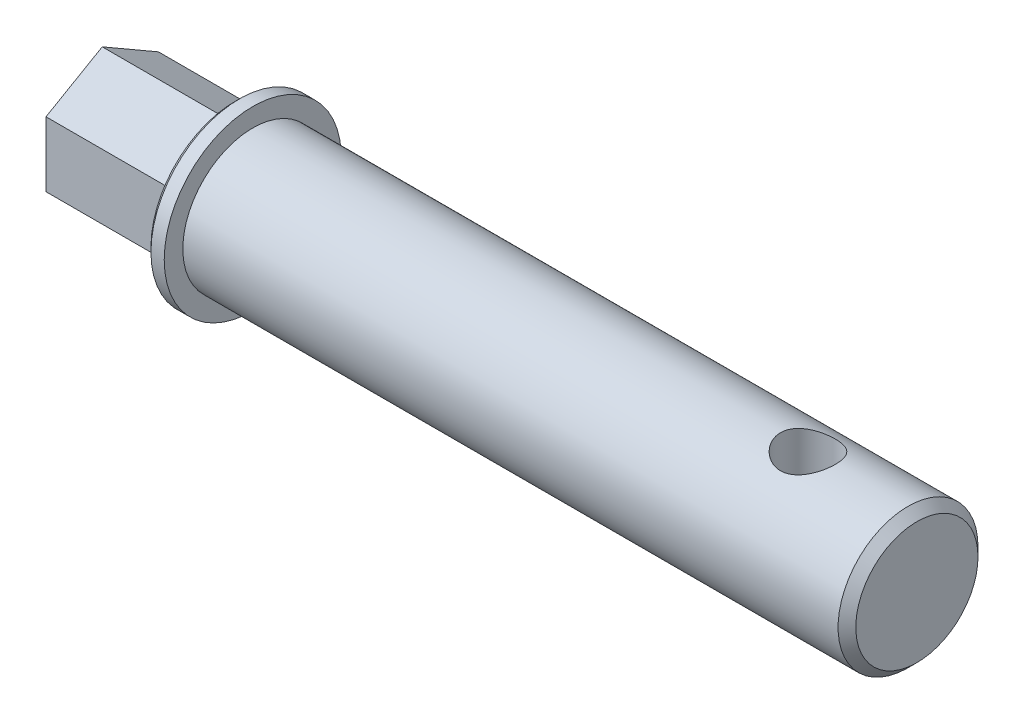
from build123d import *

# Parameters (mm, degrees)
SKETCH_1_R               = 7.9
EXTRUDE_1_DEPTH          = 75
SKETCH_3_R               = 10
EXTRUDE_2_DEPTH          = 2
EXTRUDE_3_DEPTH          = 15
CHAMFER_1_SIZE           = 0.5
M5X0_8_1_D               = 4.2
M5X0_8_1_DEPTH           = 12.4
M5X0_8_1_TIP             = 1.2618073
SKETCH_5_R               = 3.1
CUT_EXTRUDE_1_DEPTH      = 11
CUT_EXTRUDE_1_DEPTH_BACK = 11
CHAMFER_2_SIZE           = 1


with BuildPart() as part:
    # 草图1 → 凸台-拉伸1 (new body)
    with BuildSketch(Plane(origin=(0, 0, 0), x_dir=(0, 0, -1), z_dir=(1, 0, 0))):
        Circle(SKETCH_1_R)
    extrude(amount=EXTRUDE_1_DEPTH)

    # 草图3 → 凸台-拉伸2 (add)
    with BuildSketch(Plane.ZY):
        Circle(SKETCH_3_R)
    extrude(amount=EXTRUDE_2_DEPTH)

    # 草图4 → 凸台-拉伸3 (add)
    with BuildSketch(Plane.ZY.offset(2)):
        Polygon((6.35, 3.666174209), (0, 7.332348419), (-6.35, 3.666174209), (-6.35, -3.666174209), (0, -7.332348419), (6.35, -3.666174209), align=None)
    extrude(amount=EXTRUDE_3_DEPTH)

    # 倒角1
    chamfer_1_edges = [part.edges().sort_by_distance(p)[0] for p in [
        (-2, 0, -10),
    ]]
    chamfer(chamfer_1_edges, length=CHAMFER_1_SIZE)

    # M5x0.8 螺纹孔1
    with Locations(Plane.ZY.offset(17)):
        with Locations((0, 0)):
            Hole(M5X0_8_1_D / 2, depth=M5X0_8_1_DEPTH)
            with Locations((0, 0, -(M5X0_8_1_DEPTH + M5X0_8_1_TIP / 2))):  # 118° drill point
                Cone(0, M5X0_8_1_D / 2, M5X0_8_1_TIP, mode=Mode.SUBTRACT)

    # 草图5 → 切除-拉伸1 (cut, two sides)
    with BuildSketch(Plane(origin=(0, 0, 0), x_dir=(1, 0, 0), z_dir=(0, 1, 0))) as cut_extrude_1_sk:
        with Locations((62.7, 0)):
            Circle(SKETCH_5_R)
    extrude(amount=CUT_EXTRUDE_1_DEPTH, mode=Mode.SUBTRACT)
    extrude(cut_extrude_1_sk.sketch, amount=-CUT_EXTRUDE_1_DEPTH_BACK, mode=Mode.SUBTRACT)

    # 倒角2
    chamfer_2_edges = [part.edges().sort_by_distance(p)[0] for p in [
        (75, 0, 7.9),
    ]]
    chamfer(chamfer_2_edges, length=CHAMFER_2_SIZE)


solid = part.part
